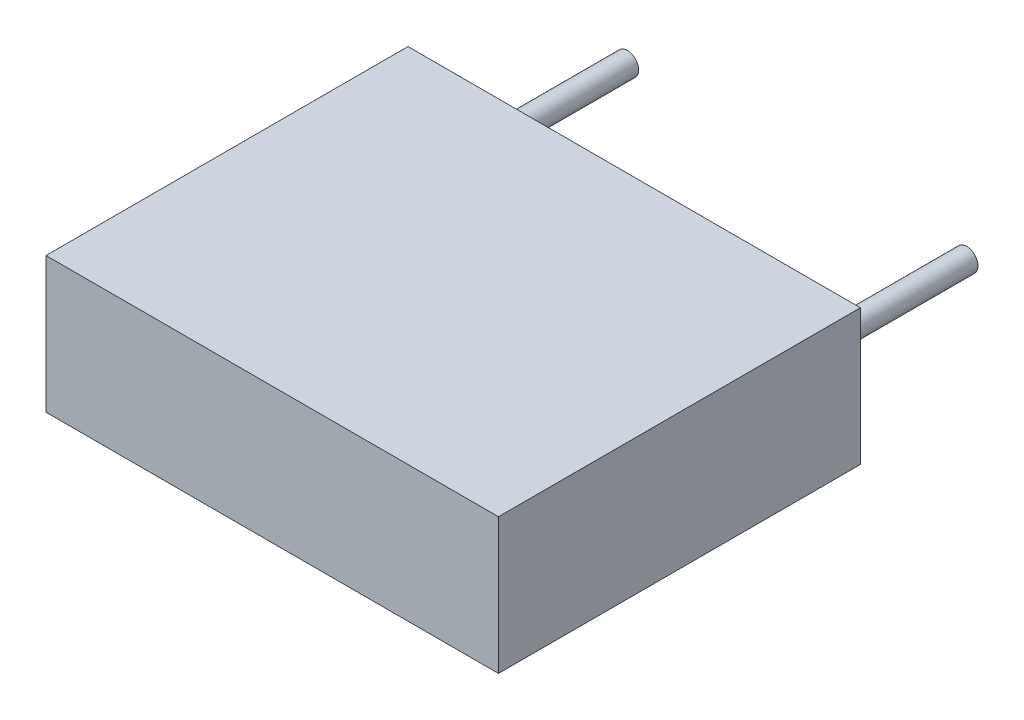
from build123d import *

# Parameters (mm, degrees)
ESQUISSE1_W        = 10
ESQUISSE1_H        = 3
BOSS_EXTRU_1_DEPTH = 8
ESQUISSE2_R        = 0.25
BOSS_EXTRU_2_DEPTH = 3.6


with BuildPart() as part:
    # Esquisse1 → Boss.-Extru.1 (new body)
    with BuildSketch(Plane.XY):
        Rectangle(ESQUISSE1_W, ESQUISSE1_H)
    extrude(amount=BOSS_EXTRU_1_DEPTH)

    # Esquisse2 → Boss.-Extru.2 (add)
    with BuildSketch(Plane(origin=(0, 0, 0), x_dir=(-1, 0, 0), z_dir=(0, 0, -1))):
        with Locations((-3.75, 0)):
            Circle(ESQUISSE2_R)
        with Locations((3.75, 0)):
            Circle(ESQUISSE2_R)
    extrude(amount=BOSS_EXTRU_2_DEPTH)


solid = part.part
